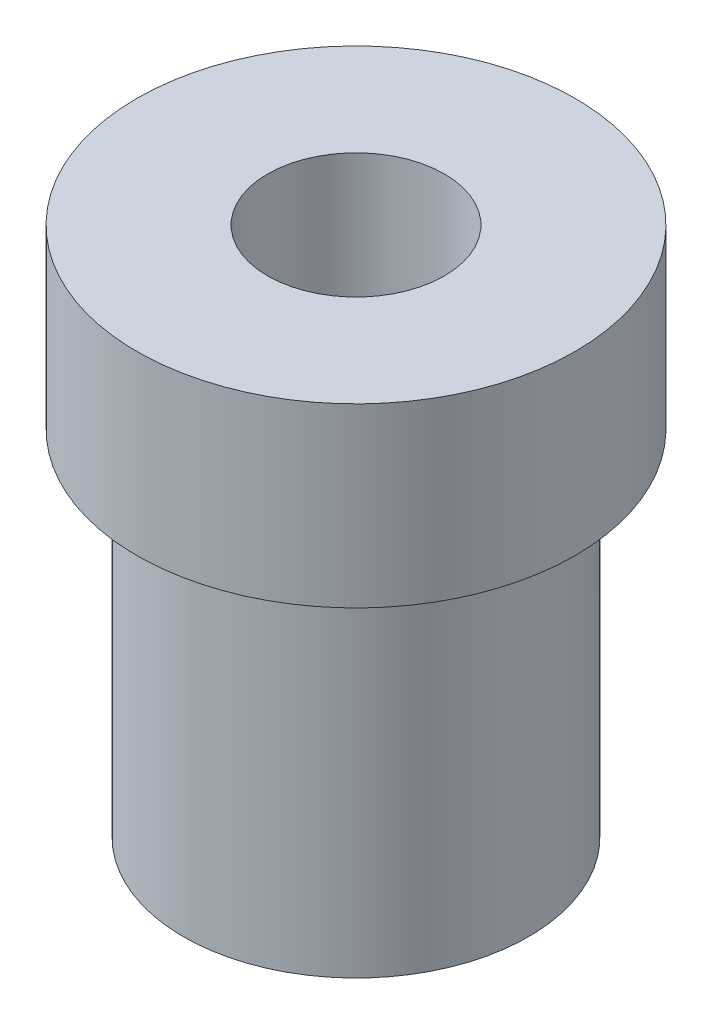
from build123d import *


with BuildPart() as part:
    # Sketch1 → Revolve1 (revolve)
    with BuildSketch(Plane.XY):
        Polygon((1.5875, 0), (1.5875, 9.525), (3.937, 9.525), (3.937, 6.35), (3.0988, 6.35), (3.0988, 0), align=None)
    revolve(axis=Axis((0, 0.120875177, 0), (0, -1, 0)))


solid = part.part
